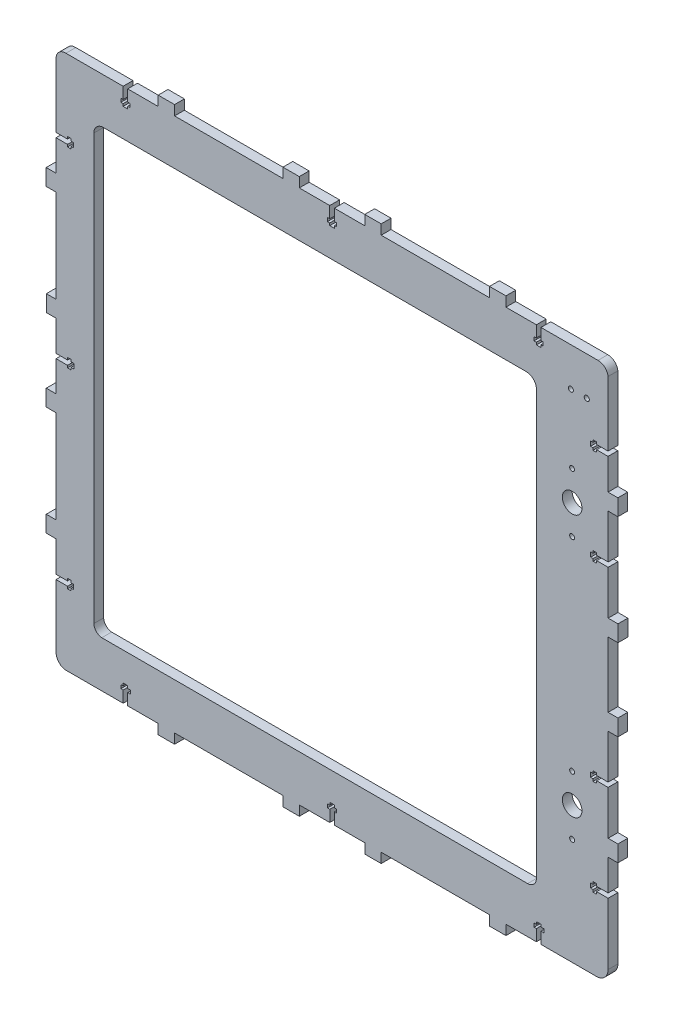
from build123d import *

# Parameters (mm, degrees)
SKETCH_1_R      = 1.499776535
SKETCH_1_R_2    = 5.99910614
SKETCH_1_R_3    = 1.549769086
EXTRUDE_1_DEPTH = 6


with BuildPart() as part:
    # Эскиз1 → Бобышка-Вытянуть1 (new body)
    with BuildSketch(Plane.XY):
        with BuildLine():
            Line((-162.382285021, 162.308435431), (-127.466462939, 162.308435431))
            Line((-127.466462939, 162.308435431), (-127.466462939, 155.298849136))
            Line((-127.466462939, 155.298849136), (-128.864855376, 155.297077675))
            Line((-128.864855376, 155.297077675), (-128.863669545, 153.098919499))
            Line((-128.863669545, 153.098919499), (-127.464951423, 153.098445342))
            Line((-127.464951423, 153.098445342), (-127.463607621, 151.656044553))
            Line((-127.463607621, 151.656044553), (-124.664288255, 151.656955119))
            Line((-124.664288255, 151.656955119), (-124.664189831, 153.099608705))
            Line((-124.664189831, 153.099608705), (-123.265334726, 153.100225766))
            Line((-123.265334726, 153.100225766), (-123.2674438, 155.299538526))
            Line((-123.2674438, 155.299538526), (-124.666462939, 155.299859173))
            Line((-124.666462939, 155.299859173), (-124.666462939, 162.315577998))
            Line((-124.666462939, 162.315577998), (-106.066462939, 162.315577998))
            Line((-106.066462939, 162.315577998), (-106.066462939, 168.315577998))
            Line((-106.066462939, 168.315577998), (-96.066462939, 168.315577998))
            Line((-96.066462939, 168.315577998), (-96.066462939, 162.316471857))
            Line((-96.066462939, 162.316471857), (-29.916462939, 162.316471857))
            Line((-29.916462939, 162.316471857), (-29.916462939, 168.316471857))
            Line((-29.916462939, 168.316471857), (-19.916462939, 168.316471857))
            Line((-19.916462939, 168.316471857), (-19.916462939, 162.320718098))
            Line((-19.916462939, 162.320718098), (-1.326462939, 162.320718098))
            Line((-1.326462939, 162.320718098), (-1.326462939, 155.305145594))
            Line((-1.326462939, 155.305145594), (-2.725921754, 155.304116609))
            Line((-2.725921754, 155.304116609), (-2.727383545, 153.105286347))
            Line((-2.727383545, 153.105286347), (-1.328170916, 153.103765038))
            Line((-1.328170916, 153.103765038), (-1.328160034, 151.661510932))
            Line((-1.328160034, 151.661510932), (1.47030276, 151.659356736))
            Line((1.47030276, 151.659356736), (1.472937425, 153.101274167))
            Line((1.472937425, 153.101274167), (2.870795507, 153.101809286))
            Line((2.870795507, 153.101809286), (2.87098851, 155.299105648))
            Line((2.87098851, 155.299105648), (1.473537061, 155.30215962))
            Line((1.473537061, 155.30215962), (1.473537061, 162.308600642))
            Line((1.473537061, 162.308600642), (20.063537061, 162.308600642))
            Line((20.063537061, 162.308600642), (20.063537061, 168.322619299))
            Line((20.063537061, 168.322619299), (30.063537061, 168.322619299))
            Line((30.063537061, 168.322619299), (30.063537061, 162.322619299))
            Line((30.063537061, 162.322619299), (96.213537061, 162.322619299))
            Line((96.213537061, 162.322619299), (96.213537061, 168.322619299))
            Line((96.213537061, 168.322619299), (106.213537061, 168.322619299))
            Line((106.213537061, 168.322619299), (106.213537061, 162.34366769))
            Line((106.213537061, 162.34366769), (124.813537061, 162.34366769))
            Line((124.813537061, 162.34366769), (124.813537061, 155.329079255))
            Line((124.813537061, 155.329079255), (123.414078503, 155.327745522))
            Line((123.414078503, 155.327745522), (123.413095533, 153.128914993))
            Line((123.413095533, 153.128914993), (124.81230846, 153.127698379))
            Line((124.81230846, 153.127698379), (124.812633409, 151.68544431))
            Line((124.812633409, 151.68544431), (127.611096606, 151.683899511))
            Line((127.611096606, 151.683899511), (127.613417277, 153.125817482))
            Line((127.613417277, 153.125817482), (129.011275209, 153.126657001))
            Line((129.011275209, 153.126657001), (129.010989142, 155.323953823))
            Line((129.010989142, 155.323953823), (127.613537061, 155.326703485))
            Line((127.613537061, 155.326703485), (127.613537061, 162.337648251))
            Line((127.613537061, 162.337648251), (162.438807528, 162.337648251))
            ThreePointArc((162.438807528, 162.337648251), (166.549989732, 160.77188103), (168.573537061, 156.865642134))
            Line((168.573537061, 156.865642134), (168.573537061, 117.437648251))
            Line((168.573537061, 117.437648251), (161.571043584, 117.437648251))
            Line((161.571043584, 117.437648251), (161.571043584, 118.837543693))
            Line((161.571043584, 118.837543693), (159.370548873, 118.837543693))
            Line((159.370548873, 118.837543693), (159.371370823, 117.437871278))
            Line((159.371370823, 117.437871278), (157.871594546, 117.436990543))
            Line((157.871594546, 117.436990543), (157.873238046, 114.638324734))
            Line((157.873238046, 114.638324734), (159.373014323, 114.639205469))
            Line((159.373014323, 114.639205469), (159.373836881, 113.238496918))
            Line((159.373836881, 113.238496918), (161.573509557, 113.238443586))
            Line((161.573509557, 113.238443586), (161.573543482, 114.637648251))
            Line((161.573543482, 114.637648251), (168.562627133, 114.637648251))
            Line((168.562627133, 114.637648251), (168.562627133, 95.737648251))
            Line((168.562627133, 95.737648251), (174.562627133, 95.737648251))
            Line((174.562627133, 95.737648251), (174.562627133, 85.737648251))
            Line((174.562627133, 85.737648251), (168.641214916, 85.737648251))
            Line((168.641214916, 85.737648251), (168.641214916, 58.837648251))
            Line((168.641214916, 58.837648251), (161.657486314, 58.837648251))
            Line((161.657486314, 58.837648251), (161.657486314, 60.237543693))
            Line((161.657486314, 60.237543693), (159.456991602, 60.237543693))
            Line((159.456991602, 60.237543693), (159.457813552, 58.837871278))
            Line((159.457813552, 58.837871278), (157.958037275, 58.836990543))
            Line((157.958037275, 58.836990543), (157.959680776, 56.038324734))
            Line((157.959680776, 56.038324734), (159.459457052, 56.039205469))
            Line((159.459457052, 56.039205469), (159.46027961, 54.638496918))
            Line((159.46027961, 54.638496918), (161.659952287, 54.638443586))
            Line((161.659952287, 54.638443586), (161.659986211, 56.037648251))
            Line((161.659986211, 56.037648251), (168.641214916, 56.037648251))
            Line((168.641214916, 56.037648251), (168.641214916, 29.137648251))
            Line((168.641214916, 29.137648251), (174.641214916, 29.137648251))
            Line((174.641214916, 29.137648251), (174.641214916, 19.137648251))
            Line((174.641214916, 19.137648251), (168.592443972, 19.137648251))
            Line((168.592443972, 19.137648251), (168.592443972, -20.662351749))
            Line((168.592443972, -20.662351749), (174.592443972, -20.662351749))
            Line((174.592443972, -20.662351749), (174.592443972, -30.662351749))
            Line((174.592443972, -30.662351749), (168.592443972, -30.662351749))
            Line((168.592443972, -30.662351749), (168.592443972, -57.562351749))
            Line((168.592443972, -57.562351749), (161.586415294, -57.562351749))
            Line((161.586415294, -57.562351749), (161.586415294, -56.162456307))
            Line((161.586415294, -56.162456307), (159.385920583, -56.162456307))
            Line((159.385920583, -56.162456307), (159.386742533, -57.562128722))
            Line((159.386742533, -57.562128722), (157.886966256, -57.563009457))
            Line((157.886966256, -57.563009457), (157.888609757, -60.361675265))
            Line((157.888609757, -60.361675265), (159.388386033, -60.36079453))
            Line((159.388386033, -60.36079453), (159.389208591, -61.761503082))
            Line((159.389208591, -61.761503082), (161.588881267, -61.761556414))
            Line((161.588881267, -61.761556414), (161.588915192, -60.362351749))
            Line((161.588915192, -60.362351749), (168.592443972, -60.362351749))
            Line((168.592443972, -60.362351749), (168.592443972, -87.262351749))
            Line((168.592443972, -87.262351749), (174.592195482, -87.262351749))
            Line((174.592195482, -87.262351749), (174.592195482, -97.262351749))
            Line((174.592195482, -97.262351749), (168.592195482, -97.262351749))
            Line((168.592195482, -97.262351749), (168.592195482, -116.162351749))
            Line((168.592195482, -116.162351749), (161.593007793, -116.162351749))
            Line((161.593007793, -116.162351749), (161.592769739, -114.762456327))
            Line((161.592769739, -114.762456327), (159.39227506, -114.762830525))
            Line((159.39227506, -114.762830525), (159.393335026, -116.16250278))
            Line((159.393335026, -116.16250278), (157.893558921, -116.163638554))
            Line((157.893558921, -116.163638554), (157.895678338, -118.962304042))
            Line((157.895678338, -118.962304042), (159.395454443, -118.961168268))
            Line((159.395454443, -118.961168268), (159.396515194, -120.361876659))
            Line((159.396515194, -120.361876659), (161.596187747, -120.361555934))
            Line((161.596187747, -120.361555934), (161.595983735, -118.962351749))
            Line((161.595983735, -118.962351749), (168.592443972, -118.962351749))
            Line((168.592443972, -118.962351749), (168.592443972, -156.700415901))
            ThreePointArc((168.592443972, -156.700415901), (166.409828255, -161.849836441), (161.191578988, -163.862351749))
            Line((161.191578988, -163.862351749), (127.632443972, -163.862351749))
            Line((127.632443972, -163.862351749), (127.632443972, -156.863393378))
            Line((127.632443972, -156.863393378), (129.324414844, -156.863393378))
            Line((129.324414844, -156.863393378), (129.32404194, -154.670504706))
            Line((129.32404194, -154.670504706), (127.631705877, -154.671786305))
            Line((127.631705877, -154.671786305), (127.630569935, -153.171788566))
            Line((127.630569935, -153.171788566), (124.831904447, -153.173907984))
            Line((124.831904447, -153.173907984), (124.833040221, -154.673684089))
            Line((124.833040221, -154.673684089), (123.43233183, -154.674744839))
            Line((123.43233183, -154.674744839), (123.432652555, -156.874417479))
            Line((123.432652555, -156.874417479), (124.832443972, -156.874213381))
            Line((124.832443972, -156.874213381), (124.832443972, -163.870671955))
            Line((124.832443972, -163.870671955), (106.232443972, -163.870671955))
            Line((106.232443972, -163.870671955), (106.232443972, -169.890505498))
            Line((106.232443972, -169.890505498), (96.232443972, -169.890505498))
            Line((96.232443972, -169.890505498), (96.232443972, -163.890505498))
            Line((96.232443972, -163.890505498), (30.082443972, -163.890505498))
            Line((30.082443972, -163.890505498), (30.082443972, -169.890505498))
            Line((30.082443972, -169.890505498), (20.082443972, -169.890505498))
            Line((20.082443972, -169.890505498), (20.082443972, -163.891399358))
            Line((20.082443972, -163.891399358), (1.492443972, -163.891399358))
            Line((1.492443972, -163.891399358), (1.492443972, -156.892440987))
            Line((1.492443972, -156.892440987), (2.891754343, -156.892440987))
            Line((2.891754343, -156.892440987), (2.891377964, -154.679114652))
            Line((2.891377964, -154.679114652), (1.491705709, -154.680174618))
            Line((1.491705709, -154.680174618), (1.490569935, -153.180398513))
            Line((1.490569935, -153.180398513), (-1.308095553, -153.182517931))
            Line((-1.308095553, -153.182517931), (-1.306959779, -154.682294036))
            Line((-1.306959779, -154.682294036), (-2.70766817, -154.683354786))
            Line((-2.70766817, -154.683354786), (-2.707347445, -156.883027425))
            Line((-2.707347445, -156.883027425), (-1.307556028, -156.882823328))
            Line((-1.307556028, -156.882823328), (-1.307556028, -163.879281902))
            Line((-1.307556028, -163.879281902), (-19.897556028, -163.879281902))
            Line((-19.897556028, -163.879281902), (-19.897556028, -169.883528143))
            Line((-19.897556028, -169.883528143), (-29.897556028, -169.883528143))
            Line((-29.897556028, -169.883528143), (-29.897556028, -163.883528143))
            Line((-29.897556028, -163.883528143), (-96.047556028, -163.883528143))
            Line((-96.047556028, -163.883528143), (-96.047556028, -169.883528143))
            Line((-96.047556028, -169.883528143), (-106.047556028, -169.883528143))
            Line((-106.047556028, -169.883528143), (-106.047556028, -163.884422002))
            Line((-106.047556028, -163.884422002), (-124.647556028, -163.884422002))
            Line((-124.647556028, -163.884422002), (-124.647556028, -156.885463632))
            Line((-124.647556028, -156.885463632), (-122.878505553, -156.885463632))
            Line((-122.878505553, -156.885463632), (-122.878878657, -154.691397319))
            Line((-122.878878657, -154.691397319), (-124.648294079, -154.69273729))
            Line((-124.648294079, -154.69273729), (-124.649430065, -153.19268118))
            Line((-124.649430065, -153.19268118), (-127.448095553, -153.194800598))
            Line((-127.448095553, -153.194800598), (-127.446959779, -154.694576703))
            Line((-127.446959779, -154.694576703), (-128.84766817, -154.695637453))
            Line((-128.84766817, -154.695637453), (-128.847347445, -156.895310092))
            Line((-128.847347445, -156.895310092), (-127.447556028, -156.895105995))
            Line((-127.447556028, -156.895105995), (-127.447556028, -163.891564569))
            Line((-127.447556028, -163.891564569), (-163.338370559, -163.891564569))
            ThreePointArc((-163.338370559, -163.891564569), (-167.000956905, -161.436911886), (-168.407556028, -157.258235367))
            Line((-168.407556028, -157.258235367), (-168.407556028, -118.991564569))
            Line((-168.407556028, -118.991564569), (-161.404707029, -118.991564569))
            Line((-161.404707029, -118.991564569), (-161.404707029, -120.39146001))
            Line((-161.404707029, -120.39146001), (-159.204212318, -120.39146001))
            Line((-159.204212318, -120.39146001), (-159.205033828, -118.992535911))
            Line((-159.205033828, -118.992535911), (-157.684362147, -118.991642905))
            Line((-157.684362147, -118.991642905), (-157.689437775, -116.191642905))
            Line((-157.689437775, -116.191642905), (-159.209014212, -116.192535267))
            Line((-159.209014212, -116.192535267), (-159.20983677, -114.791826469))
            Line((-159.20983677, -114.791826469), (-161.409509432, -114.791773136))
            Line((-161.409509432, -114.791773136), (-161.409543371, -116.191564569))
            Line((-161.409543371, -116.191564569), (-168.407804518, -116.191564569))
            Line((-168.407804518, -116.191564569), (-168.407804518, -97.431564569))
            Line((-168.407804518, -97.431564569), (-174.407804518, -97.431564569))
            Line((-174.407804518, -97.431564569), (-174.407804518, -87.431564569))
            Line((-174.407804518, -87.431564569), (-168.407556028, -87.431564569))
            Line((-168.407556028, -87.431564569), (-168.407556028, -30.781564569))
            Line((-168.407556028, -30.781564569), (-174.407556028, -30.781564569))
            Line((-174.407556028, -30.781564569), (-174.407556028, -20.781564569))
            Line((-174.407556028, -20.781564569), (-168.407556028, -20.781564569))
            Line((-168.407556028, -20.781564569), (-168.407556028, -2.191564569))
            Line((-168.407556028, -2.191564569), (-161.410385376, -2.191564569))
            Line((-161.410385376, -2.191564569), (-161.410147322, -3.59145999))
            Line((-161.410147322, -3.59145999), (-159.209652643, -3.591085793))
            Line((-159.209652643, -3.591085793), (-159.210712608, -2.191413538))
            Line((-159.210712608, -2.191413538), (-157.416000436, -2.19005441))
            Line((-157.416000436, -2.19005441), (-157.425703992, 0.764902156))
            Line((-157.425703992, 0.764902156), (-159.162809024, 0.763586653))
            Line((-159.162809024, 0.763586653), (-159.163751828, 2.008547574))
            Line((-159.163751828, 2.008547574), (-161.363424467, 2.008226849))
            Line((-161.363424467, 2.008226849), (-161.363220369, 0.608435431))
            Line((-161.363220369, 0.608435431), (-168.407556028, 0.608435431))
            Line((-168.407556028, 0.608435431), (-168.407556028, 19.198435431))
            Line((-168.407556028, 19.198435431), (-174.358785084, 19.198435431))
            Line((-174.358785084, 19.198435431), (-174.358785084, 29.198435431))
            Line((-174.358785084, 29.198435431), (-168.358785084, 29.198435431))
            Line((-168.358785084, 29.198435431), (-168.358785084, 85.848435431))
            Line((-168.358785084, 85.848435431), (-174.437372867, 85.848435431))
            Line((-174.437372867, 85.848435431), (-174.437372867, 95.848435431))
            Line((-174.437372867, 95.848435431), (-168.437372867, 95.848435431))
            Line((-168.437372867, 95.848435431), (-168.437372867, 114.608435431))
            Line((-168.437372867, 114.608435431), (-161.406652343, 114.608435431))
            Line((-161.406652343, 114.608435431), (-161.406652343, 113.20853999))
            Line((-161.406652343, 113.20853999), (-159.206157632, 113.20853999))
            Line((-159.206157632, 113.20853999), (-159.206979581, 114.608212405))
            Line((-159.206979581, 114.608212405), (-157.706725947, 114.60909342))
            Line((-157.706725947, 114.60909342), (-157.708846286, 117.408974958))
            Line((-157.708846286, 117.408974958), (-159.208622847, 117.407839183))
            Line((-159.208622847, 117.407839183), (-159.209683598, 118.808547574))
            Line((-159.209683598, 118.808547574), (-161.409356237, 118.808226849))
            Line((-161.409356237, 118.808226849), (-161.409152139, 117.408435431))
            Line((-161.409152139, 117.408435431), (-168.426462939, 117.408435431))
            Line((-168.426462939, 117.408435431), (-168.426462939, 156.695916071))
            ThreePointArc((-168.426462939, 156.695916071), (-166.577388219, 160.765406451), (-162.382285021, 162.308435431))
        make_face()
        with Locations((146.641214916, 97.237648251)):
            Circle(SKETCH_1_R, mode=Mode.SUBTRACT)
        with Locations((146.641214916, 61.237648251)):
            Circle(SKETCH_1_R, mode=Mode.SUBTRACT)
        with Locations((146.641214916, 79.237648251)):
            Circle(SKETCH_1_R_2, mode=Mode.SUBTRACT)
        with Locations((146.641214916, -98.762351749)):
            Circle(SKETCH_1_R, mode=Mode.SUBTRACT)
        with Locations((146.641214916, -80.762351749)):
            Circle(SKETCH_1_R_2, mode=Mode.SUBTRACT)
        with Locations((146.641214916, -62.762351749)):
            Circle(SKETCH_1_R, mode=Mode.SUBTRACT)
        with Locations((145.873537061, 138.837648251)):
            Circle(SKETCH_1_R_3, mode=Mode.SUBTRACT)
        with Locations((155.573537061, 138.837648251)):
            Circle(SKETCH_1_R_3, mode=Mode.SUBTRACT)
        with BuildLine():
            Line((-145.346896139, 128.637688118), (-145.346896139, -130.703427214))
            ThreePointArc((-145.346896139, -130.703427214), (-143.86599811, -134.143169764), (-140.491160122, -135.766547824))
            Line((-140.491160122, -135.766547824), (119.465267875, -135.766547824))
            ThreePointArc((119.465267875, -135.766547824), (123.199713749, -134.248357992), (124.815536593, -130.555107))
            Line((124.815536593, -130.555107), (124.815536593, 128.790043446))
            ThreePointArc((124.815536593, 128.790043446), (122.861386425, 132.837018973), (118.680884629, 134.486297158))
            Line((118.680884629, 134.486297158), (-139.349726494, 134.486297158))
            ThreePointArc((-139.349726494, 134.486297158), (-143.580749241, 132.825735736), (-145.346896139, 128.637688118))
        make_face(mode=Mode.SUBTRACT)
    extrude(amount=EXTRUDE_1_DEPTH)


solid = part.part
